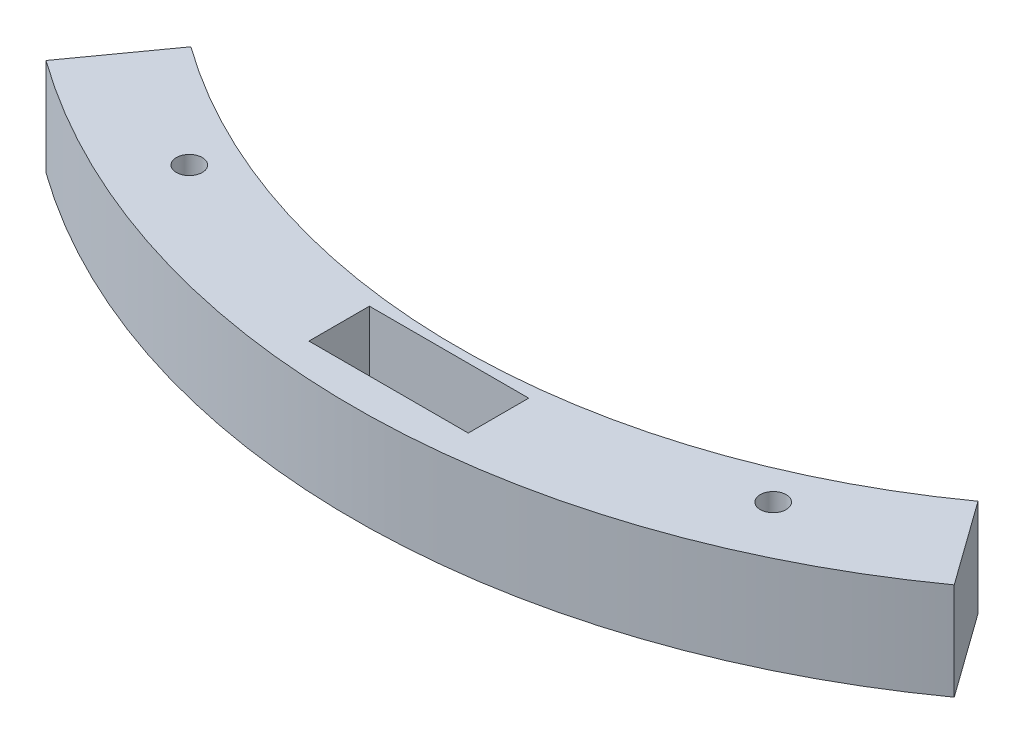
from build123d import *

# Parameters (mm, degrees)
CROQUIS1_R              = 1
CROQUIS1_W              = 10.28
CROQUIS1_H              = 2.66
SALIENTE_EXTRUIR1_DEPTH = 7.5
CROQUIS2_W              = 12.28
CROQUIS2_H              = 4.66
CORTAR_EXTRUIR1_DEPTH   = 5.5


with BuildPart() as part:
    # Croquis1 → Saliente-Extruir1 (new body)
    with BuildSketch(Plane(origin=(0, 0, 0), x_dir=(1, 0, 0), z_dir=(0, 1, 0))):
        with BuildLine():
            Line((35, -48.733971724), (30.333333333, -42.236108828))
            ThreePointArc((30.333333333, -42.236108828), (0, -52), (-30.333333333, -42.236108828))
            Line((-30.333333333, -42.236108828), (-35, -48.733971724))
            ThreePointArc((-35, -48.733971724), (0, -60), (35, -48.733971724))
        make_face()
        with Locations((-22.5, -50.18714975)):
            Circle(CROQUIS1_R, mode=Mode.SUBTRACT)
        with Locations((22.5, -50.18714975)):
            Circle(CROQUIS1_R, mode=Mode.SUBTRACT)
        with Locations((0, -55)):
            Rectangle(CROQUIS1_W, CROQUIS1_H, mode=Mode.SUBTRACT)
    extrude(amount=SALIENTE_EXTRUIR1_DEPTH)

    # Croquis2 → Cortar-Extruir1 (cut)
    with BuildSketch(Plane(origin=(0, 7.5, 0), x_dir=(1, 0, 0), z_dir=(0, 1, 0))):
        with Locations((0, -55)):
            Rectangle(CROQUIS2_W, CROQUIS2_H)
    extrude(amount=-CORTAR_EXTRUIR1_DEPTH, mode=Mode.SUBTRACT)


solid = part.part
